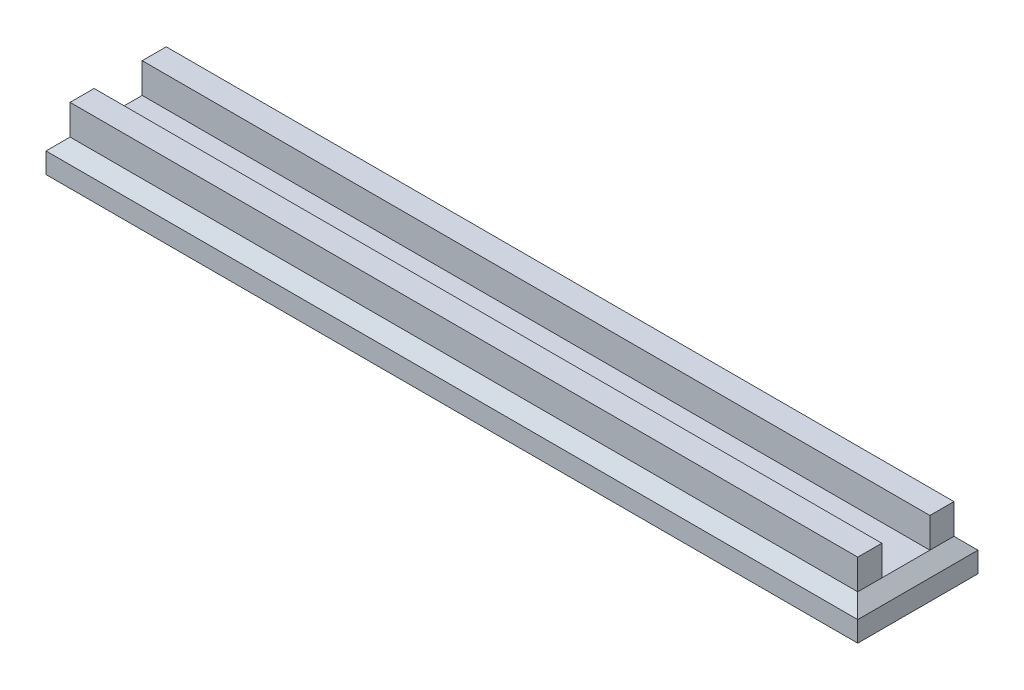
from build123d import *

# Parameters (mm, degrees)
SKETCH1_W           = 135
SKETCH1_H           = 20
BOSS_EXTRUDE1_DEPTH = 5.4
CHAMFER1_SIZE       = 2
SKETCH2_W           = 131
SKETCH2_H           = 4
BOSS_EXTRUDE2_DEPTH = 5


with BuildPart() as part:
    # Sketch1 → Boss-Extrude1 (new body)
    with BuildSketch(Plane(origin=(0, 0, 0), x_dir=(1, 0, 0), z_dir=(0, 1, 0))):
        Rectangle(SKETCH1_W, SKETCH1_H)
    extrude(amount=BOSS_EXTRUDE1_DEPTH)

    # Chamfer1
    chamfer1_edges = [part.edges().sort_by_distance(p)[0] for p in [
        (-67.5, 5.4, 0),
        (0, 5.4, 10),
        (67.5, 5.4, 0),
        (0, 5.4, -10),
    ]]
    chamfer(chamfer1_edges, length=CHAMFER1_SIZE)

    # Sketch2 → Boss-Extrude2 (add)
    with BuildSketch(Plane(origin=(0, 5.4, 0), x_dir=(1, 0, 0), z_dir=(0, 1, 0))):
        with Locations((0, 6)):
            Rectangle(SKETCH2_W, SKETCH2_H)
        with Locations((0, -6)):
            Rectangle(SKETCH2_W, SKETCH2_H)
    extrude(amount=BOSS_EXTRUDE2_DEPTH)


solid = part.part
